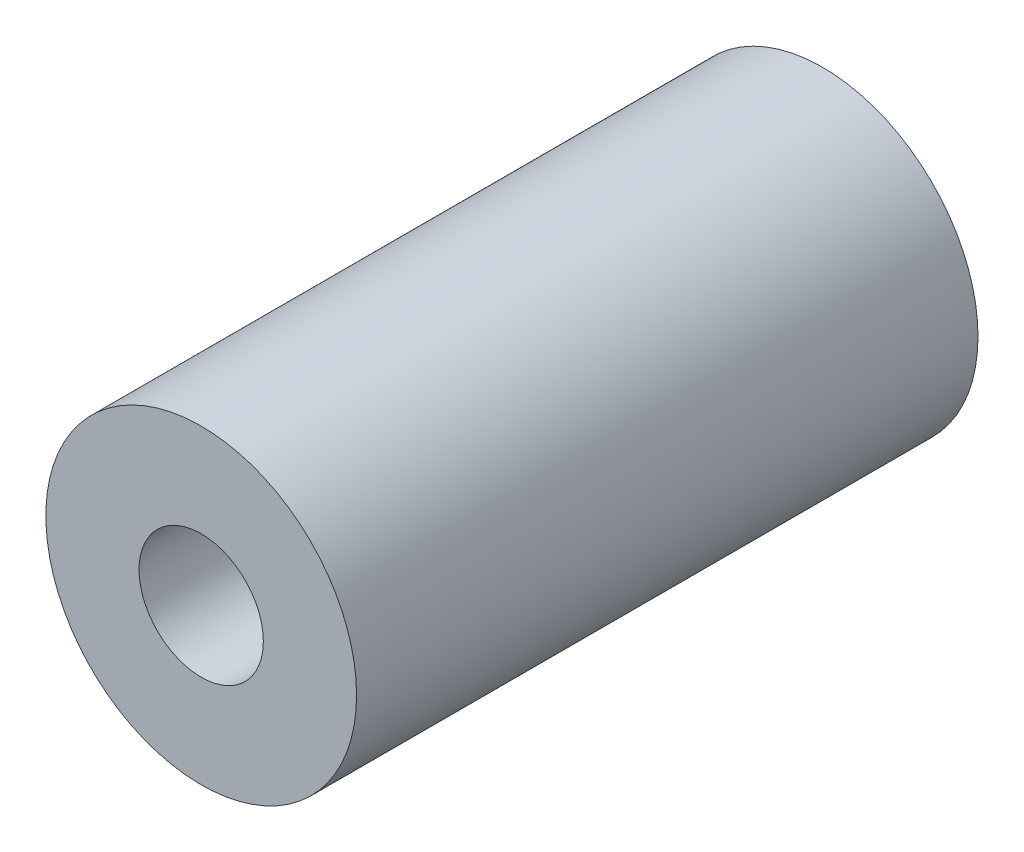
from build123d import *

# Parameters (mm, degrees)
SKIZZE1_R                       = 2.5
SKIZZE1_R_2                     = 1
AUFSATZ_LINEAR_AUSTRAGEN1_DEPTH = 10


with BuildPart() as part:
    # Skizze1 → Aufsatz-Linear austragen1 (new body)
    with BuildSketch(Plane.XY):
        Circle(SKIZZE1_R)
        Circle(SKIZZE1_R_2, mode=Mode.SUBTRACT)
    extrude(amount=-AUFSATZ_LINEAR_AUSTRAGEN1_DEPTH)


solid = part.part
